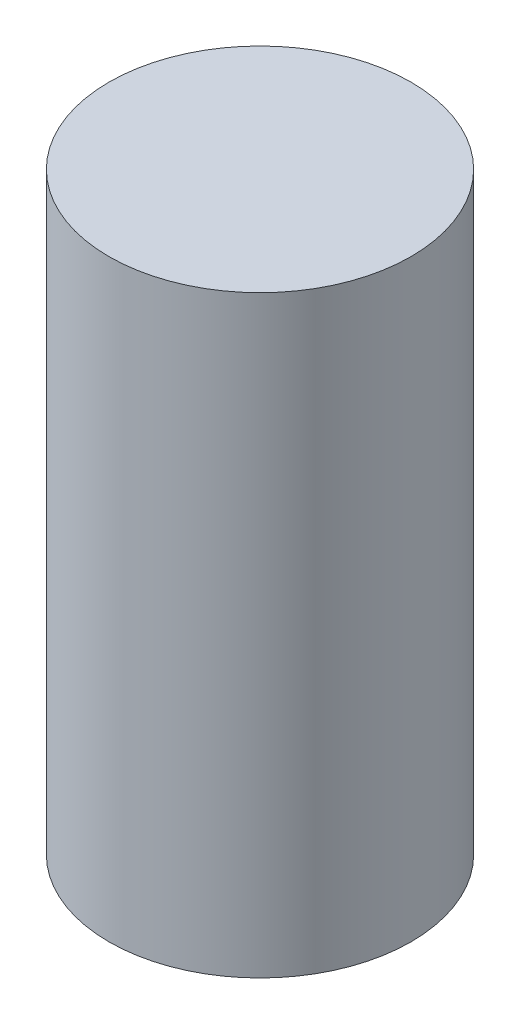
from build123d import *

# Parameters (mm, degrees)
SKETCH1_R           = 280
BOSS_EXTRUDE1_DEPTH = 1100


with BuildPart() as part:
    # Sketch1 → Boss-Extrude1 (new body)
    with BuildSketch(Plane(origin=(0, 0, 0), x_dir=(1, 0, 0), z_dir=(0, 1, 0))):
        Circle(SKETCH1_R)
    extrude(amount=BOSS_EXTRUDE1_DEPTH)


solid = part.part
